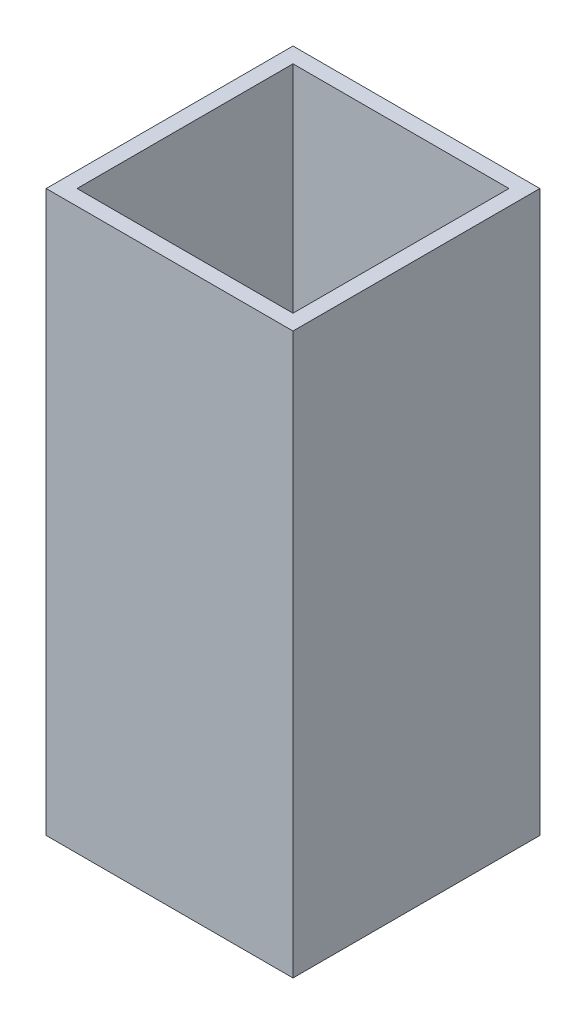
from build123d import *

# Parameters (mm, degrees)
SKETCH1_W           = 25.4
SKETCH1_H           = 25.4
SKETCH1_W_2         = 22.225
SKETCH1_H_2         = 22.225
BOSS_EXTRUDE1_DEPTH = 57.658


with BuildPart() as part:
    # Sketch1 → Boss-Extrude1 (new body)
    with BuildSketch(Plane(origin=(0, 0, 0), x_dir=(1, 0, 0), z_dir=(0, 1, 0))):
        Rectangle(SKETCH1_W, SKETCH1_H)
        Rectangle(SKETCH1_W_2, SKETCH1_H_2, mode=Mode.SUBTRACT)
    extrude(amount=BOSS_EXTRUDE1_DEPTH)


solid = part.part
